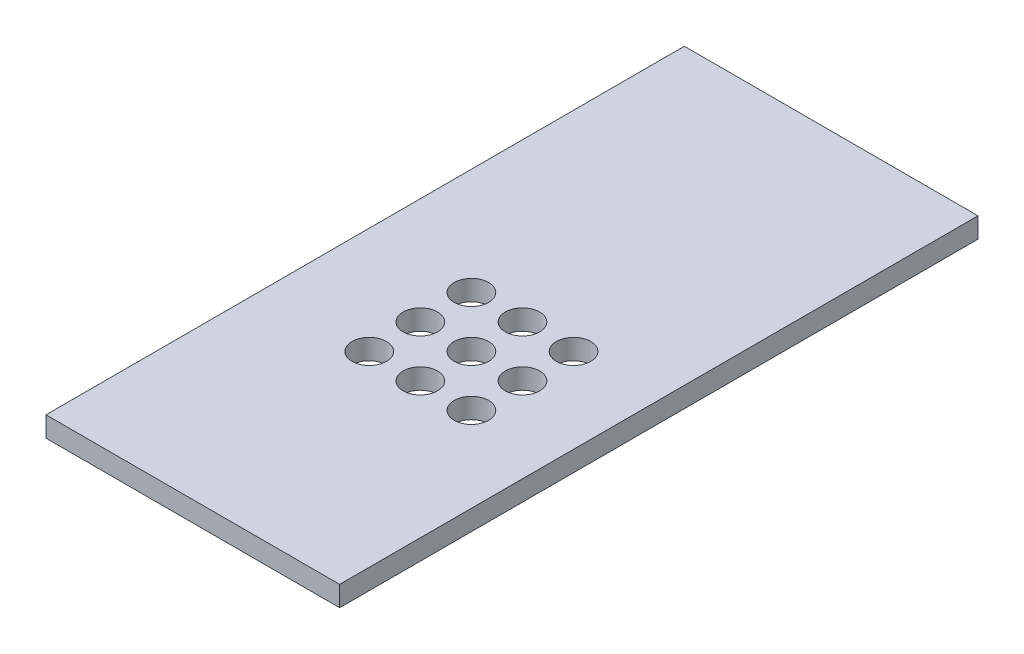
from build123d import *

# Parameters (mm, degrees)
SKETCH1_W           = 23
SKETCH1_H           = 50
SKETCH1_R           = 1.35
BOSS_EXTRUDE1_DEPTH = 1.5875


with BuildPart() as part:
    # Sketch1 → Boss-Extrude1 (new body)
    with BuildSketch(Plane(origin=(0, 0, 0), x_dir=(1, 0, 0), z_dir=(0, 1, 0))):
        with Locations((11.5, 25)):
            Rectangle(SKETCH1_W, SKETCH1_H)
        with Locations((8.36, 16.96)):
            Circle(SKETCH1_R, mode=Mode.SUBTRACT)
        with Locations((12.36, 16.96)):
            Circle(SKETCH1_R, mode=Mode.SUBTRACT)
        with Locations((16.36, 16.96)):
            Circle(SKETCH1_R, mode=Mode.SUBTRACT)
        with Locations((8.36, 20.96)):
            Circle(SKETCH1_R, mode=Mode.SUBTRACT)
        with Locations((12.36, 20.96)):
            Circle(SKETCH1_R, mode=Mode.SUBTRACT)
        with Locations((16.36, 20.96)):
            Circle(SKETCH1_R, mode=Mode.SUBTRACT)
        with Locations((8.36, 24.96)):
            Circle(SKETCH1_R, mode=Mode.SUBTRACT)
        with Locations((12.36, 24.96)):
            Circle(SKETCH1_R, mode=Mode.SUBTRACT)
        with Locations((16.36, 24.96)):
            Circle(SKETCH1_R, mode=Mode.SUBTRACT)
    extrude(amount=BOSS_EXTRUDE1_DEPTH)


solid = part.part
